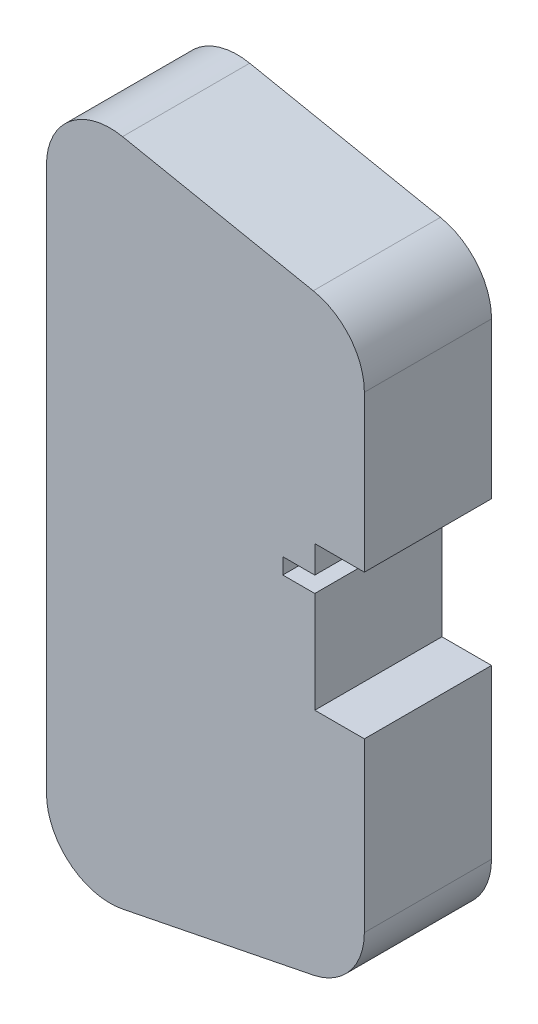
from build123d import *

# Parameters (mm, degrees)
BOSS_EXTRUDE1_DEPTH = 20
SKETCH5_W           = 9
SKETCH5_H           = 1.454272164
CUT_EXTRUDE4_DEPTH  = 10
SKETCH6_R           = 0.5
CUT_EXTRUDE5_DEPTH  = 5
CUT_EXTRUDE6_DEPTH  = 21
SKETCH11_R          = 1
CUT_EXTRUDE7_DEPTH  = 5


with BuildPart() as part:
    # Sketch1 → Boss-Extrude1 (new body)
    with BuildSketch(Plane.XY):
        with BuildLine():
            Line((0, 42.801960973), (0, -42.801960973))
            ThreePointArc((0, -42.801960973), (3.660110944, -50.535382386), (11.961161351, -52.60776773))
            Line((11.961161351, -52.60776773), (41.961161351, -46.60776773))
            ThreePointArc((41.961161351, -46.60776773), (47.733421413, -43.141850029), (50, -36.801960973))
            Line((50, -36.801960973), (50, 36.801960973))
            ThreePointArc((50, 36.801960973), (47.733421413, 43.141850029), (41.961161351, 46.60776773))
            Line((41.961161351, 46.60776773), (11.961161351, 52.60776773))
            ThreePointArc((11.961161351, 52.60776773), (3.660110944, 50.535382386), (0, 42.801960973))
        make_face()
    extrude(amount=BOSS_EXTRUDE1_DEPTH)

    # Sketch5 → Cut-Extrude4 (cut)
    with BuildSketch(Plane.ZY):
        with Locations((10, 16.569972364)):
            Rectangle(SKETCH5_W, SKETCH5_H)
    extrude(amount=-CUT_EXTRUDE4_DEPTH, mode=Mode.SUBTRACT)

    # Sketch6 → Cut-Extrude5 (cut)
    with BuildSketch(Plane.XZ.offset(-17.297108446)):
        with Locations((2.644871575, 10)):
            Circle(SKETCH6_R)
    extrude(amount=-CUT_EXTRUDE5_DEPTH, mode=Mode.SUBTRACT)

    # Sketch9 → Cut-Extrude6 (cut, through all)
    with BuildSketch(Plane.XY.offset(20)):
        Polygon((42.2, 5.497108446), (42.2, -10.402891554), (50, -10.402891554), (50, 12.297108446), (42.2, 12.297108446), (42.2, 7.997108446), (37.17, 7.997108446), (37.17, 5.497108446), align=None)
    extrude(amount=-CUT_EXTRUDE6_DEPTH, mode=Mode.SUBTRACT)

    # Sketch11 → Cut-Extrude7 (cut)
    with BuildSketch(Plane(origin=(0, 7.997108446, 0), x_dir=(-1, 0, 0), z_dir=(0, -1, 0))):
        with Locations((-39.9, -10)):
            Circle(SKETCH11_R)
    extrude(amount=-CUT_EXTRUDE7_DEPTH, mode=Mode.SUBTRACT)


solid = part.part
